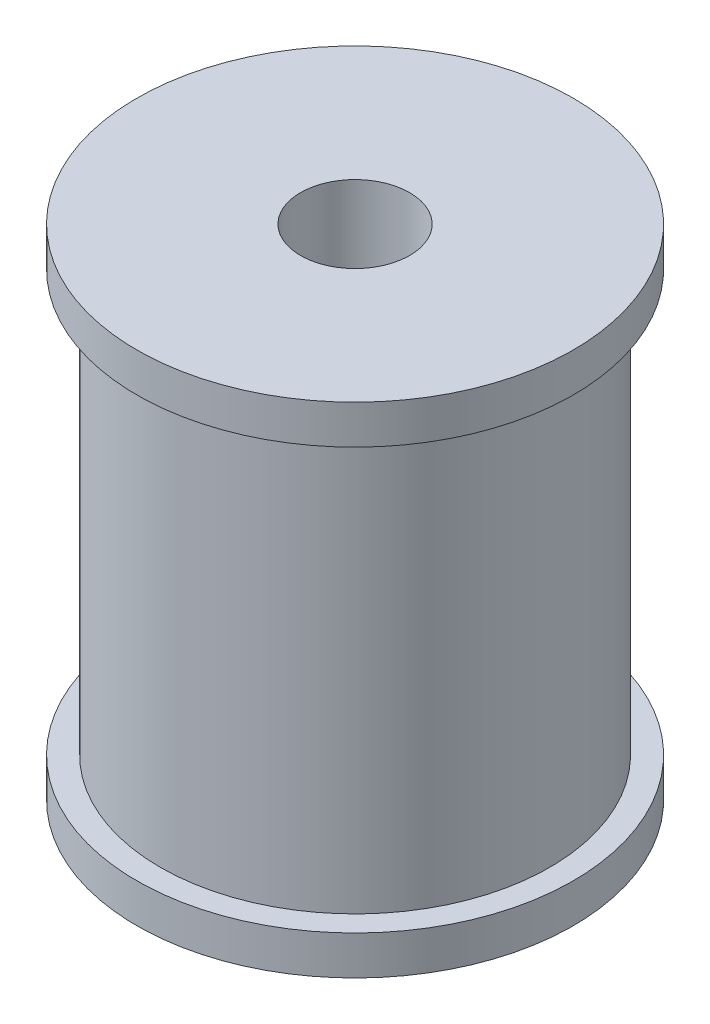
from build123d import *


with BuildPart() as part:
    # Sketch3 → Revolve1 (revolve)
    with BuildSketch(Plane.XY):
        Polygon((3.5, 32), (3.5, 0), (14, 0), (14, 2.5), (12.5, 2.5), (12.5, 29.5), (14, 29.5), (14, 32), align=None)
    revolve(axis=Axis((0, 0, 0), (0, 1, 0)))


solid = part.part
